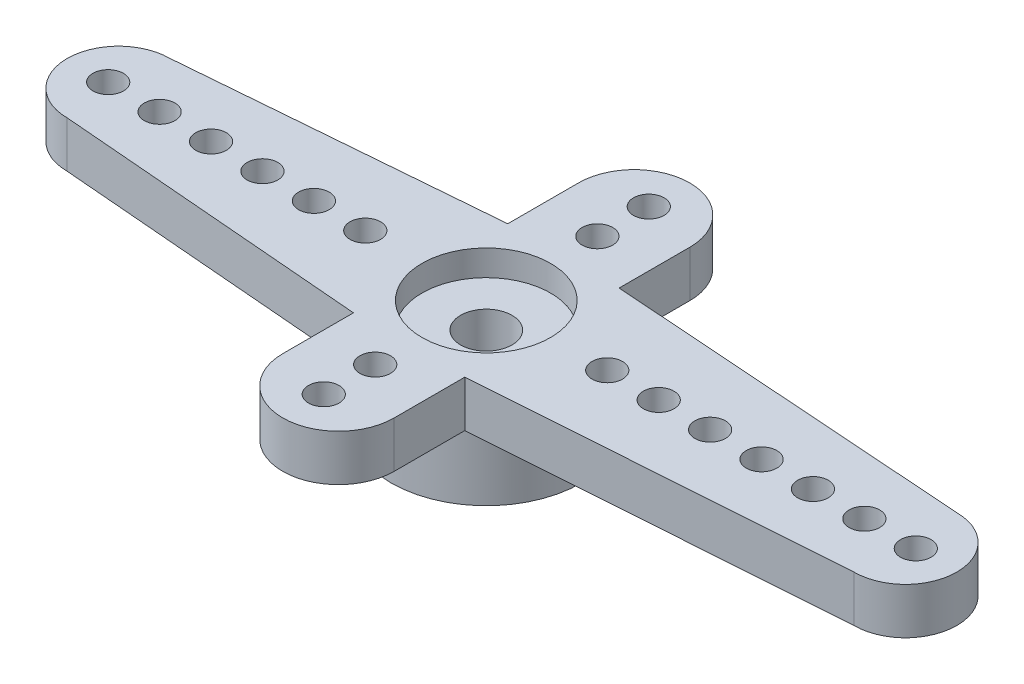
from build123d import *

# Parameters (mm, degrees)
CROQUIS1_R              = 3.7
SALIENTE_EXTRUIR2_DEPTH = 4.3
CROQUIS2_R              = 2.5
CORTAR_EXTRUIR1_DEPTH   = 1.5
CROQUIS3_R              = 2.5
CORTAR_EXTRUIR2_DEPTH   = 1
CROQUIS4_R              = 1
CORTAR_EXTRUIR3_DEPTH   = 1.8
SALIENTE_EXTRUIR3_DEPTH = 1.8
CROQUIS6_R              = 0.595
CORTAR_EXTRUIR4_DEPTH   = 1.8
CROQUIS7_R              = 0.595
SALIENTE_EXTRUIR4_DEPTH = 1.8


with BuildPart() as part:
    # Croquis1 → Saliente-Extruir2 (new body)
    with BuildSketch(Plane(origin=(0, 0, 0), x_dir=(1, 0, 0), z_dir=(0, 1, 0))):
        Circle(CROQUIS1_R)
    extrude(amount=SALIENTE_EXTRUIR2_DEPTH)

    # Croquis2 → Cortar-Extruir1 (cut)
    with BuildSketch(Plane.XZ):
        Circle(CROQUIS2_R)
    extrude(amount=-CORTAR_EXTRUIR1_DEPTH, mode=Mode.SUBTRACT)

    # Croquis3 → Cortar-Extruir2 (cut)
    with BuildSketch(Plane(origin=(0, 4.3, 0), x_dir=(1, 0, 0), z_dir=(0, 1, 0))):
        Circle(CROQUIS3_R)
    extrude(amount=-CORTAR_EXTRUIR2_DEPTH, mode=Mode.SUBTRACT)

    # Croquis4 → Cortar-Extruir3 (cut)
    with BuildSketch(Plane(origin=(0, 3.3, 0), x_dir=(1, 0, 0), z_dir=(0, 1, 0))):
        Circle(CROQUIS4_R)
    extrude(amount=-CORTAR_EXTRUIR3_DEPTH, mode=Mode.SUBTRACT)

    # Croquis5 → Saliente-Extruir3 (add)
    with BuildSketch(Plane(origin=(0, 4.3, 0), x_dir=(1, 0, 0), z_dir=(0, 1, 0))):
        with BuildLine():
            Line((-2.16564, 3.000000565), (-3.120237459, 0))
            Line((-3.120237459, 0), (-2.16564, -3.000000565))
            Line((-2.16564, -3.000000565), (-14.3, -2))
            ThreePointArc((-14.3, -2), (-16.3, 0), (-14.3, 2))
            Line((-14.3, 2), (-2.16564, 3.000000565))
        make_face()
        with BuildLine():
            Line((3.120237459, 0), (2.16564, -3.000000565))
            Line((2.16564, -3.000000565), (16.3, -2))
            ThreePointArc((16.3, -2), (18.3, 0), (16.3, 2))
            Line((16.3, 2), (2.16564, 3.000000565))
            Line((2.16564, 3.000000565), (3.120237459, 0))
        make_face()
    extrude(amount=-SALIENTE_EXTRUIR3_DEPTH)

    # Croquis6 → Cortar-Extruir4 (cut)
    with BuildSketch(Plane(origin=(0, 4.3, 0), x_dir=(1, 0, 0), z_dir=(0, 1, 0))):
        with Locations((-14.705, 0)):
            Circle(CROQUIS6_R)
        with Locations((-12.705, 0)):
            Circle(CROQUIS6_R)
        with Locations((-10.705, 0)):
            Circle(CROQUIS6_R)
        with Locations((-8.705, 0)):
            Circle(CROQUIS6_R)
        with Locations((-6.705, 0)):
            Circle(CROQUIS6_R)
        with Locations((-4.705, 0)):
            Circle(CROQUIS6_R)
        with Locations((14.705, 0)):
            Circle(CROQUIS6_R)
        with Locations((12.705, 0)):
            Circle(CROQUIS6_R)
        with Locations((10.705, 0)):
            Circle(CROQUIS6_R)
        with Locations((8.705, 0)):
            Circle(CROQUIS6_R)
        with Locations((6.705, 0)):
            Circle(CROQUIS6_R)
        with Locations((4.705, 0)):
            Circle(CROQUIS6_R)
        with Locations((16.705, 0)):
            Circle(CROQUIS6_R)
    extrude(amount=-CORTAR_EXTRUIR4_DEPTH, mode=Mode.SUBTRACT)

    # Croquis7 → Saliente-Extruir4 (add)
    with BuildSketch(Plane(origin=(0, 4.3, 0), x_dir=(1, 0, 0), z_dir=(0, 1, 0))):
        with BuildLine():
            Line((-2.16564, 3.000000565), (2.16564, 3.000000565))
            Line((2.16564, 3.000000565), (2.16564, 5.750000565))
            ThreePointArc((2.16564, 5.750000565), (0, 7.915640565), (-2.16564, 5.750000565))
            Line((-2.16564, 5.750000565), (-2.16564, 3.000000565))
        make_face()
        with Locations((0, 6.320640565)):
            Circle(CROQUIS7_R, mode=Mode.SUBTRACT)
        with Locations((0, 4.320640565)):
            Circle(CROQUIS7_R, mode=Mode.SUBTRACT)
        with BuildLine():
            Line((2.16564, -3.000000565), (2.16564, -5.750000565))
            ThreePointArc((2.16564, -5.750000565), (0, -7.915640565), (-2.16564, -5.750000565))
            Line((-2.16564, -5.750000565), (-2.16564, -3.000000565))
            Line((-2.16564, -3.000000565), (2.16564, -3.000000565))
        make_face()
        with Locations((0, -4.320640565)):
            Circle(CROQUIS7_R, mode=Mode.SUBTRACT)
        with Locations((0, -6.320640565)):
            Circle(CROQUIS7_R, mode=Mode.SUBTRACT)
    extrude(amount=-SALIENTE_EXTRUIR4_DEPTH)


solid = part.part
